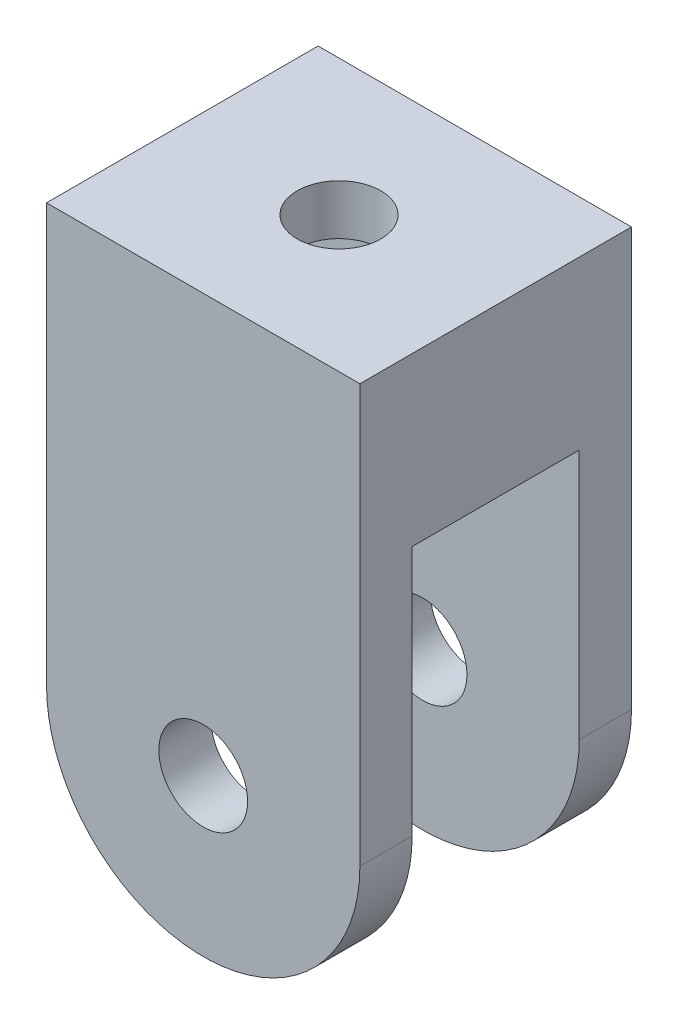
from build123d import *

# Parameters (mm, degrees)
SKETCH1_R           = 2.125
BOSS_EXTRUDE1_DEPTH = 2.5
SKETCH2_W           = 15
SKETCH2_H           = 8
BOSS_EXTRUDE2_DEPTH = 8
CUT_EXTRUDE1_REACH  = 29.5
SKETCH4_R           = 2
SKETCH6_W           = 7.25
SKETCH6_H           = 3.25
CUT_EXTRUDE2_DEPTH  = 11.5


with BuildPart() as part:
    # Sketch1 → Boss-Extrude1 (new body)
    with BuildSketch(Plane.XY):
        with BuildLine():
            Line((2.5, 10), (2.5, 30))
            Line((2.5, 30), (17.5, 30))
            Line((17.5, 30), (17.5, 10))
            ThreePointArc((17.5, 10), (10, 2.5), (2.5, 10))
        make_face()
        with Locations((10, 10)):
            Circle(SKETCH1_R, mode=Mode.SUBTRACT)
    boss_extrude1 = extrude(amount=BOSS_EXTRUDE1_DEPTH)

    # Sketch2 → Boss-Extrude2 (add)
    with BuildSketch(Plane(origin=(0, 0, 0), x_dir=(-1, 0, 0), z_dir=(0, 0, -1))):
        with Locations((-10, 26)):
            Rectangle(SKETCH2_W, SKETCH2_H)
    extrude(amount=BOSS_EXTRUDE2_DEPTH)

    # Mirror1: Boss-Extrude1 across plane
    add(boss_extrude1.mirror(Plane.XY.offset(-4)))

    # Sketch4 → Cut-Extrude1 (cut, up to next)
    with BuildSketch(Plane(origin=(0, 30, 0), x_dir=(1, 0, 0), z_dir=(0, 1, 0)), mode=Mode.PRIVATE) as cut_extrude1_sk1:
        with Locations((10, 4)):
            Circle(SKETCH4_R)
    cut_extrude1_tool1 = extrude(cut_extrude1_sk1.sketch, amount=-CUT_EXTRUDE1_REACH, mode=Mode.PRIVATE) & part.part
    add(cut_extrude1_tool1.solids().sort_by_distance((10, 30, -4))[0], mode=Mode.SUBTRACT)

    # Sketch6 → Cut-Extrude2 (cut)
    with BuildSketch(Plane.ZY.offset(-2.5)):
        with Locations((-4, 25.975)):
            Rectangle(SKETCH6_W, SKETCH6_H)
    extrude(amount=-CUT_EXTRUDE2_DEPTH, mode=Mode.SUBTRACT)


solid = part.part
